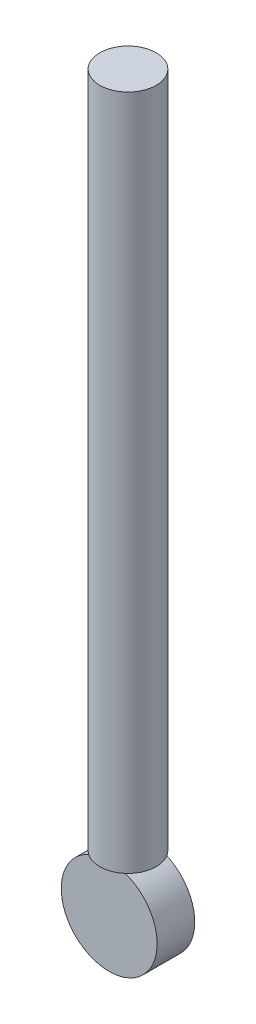
from build123d import *

# Parameters (mm, degrees)
SKETCH1_R           = 9.525
BOSS_EXTRUDE1_DEPTH = 228.6
SKETCH3_R           = 16.198016886
BOSS_EXTRUDE2_DEPTH = 6.35


with BuildPart() as part:
    # Sketch1 → Boss-Extrude1 (new body)
    with BuildSketch(Plane(origin=(0, 0, 0), x_dir=(1, 0, 0), z_dir=(0, 1, 0))):
        Circle(SKETCH1_R)
    extrude(amount=BOSS_EXTRUDE1_DEPTH)

    # Sketch3 → Boss-Extrude2 (add, symmetric)
    with BuildSketch(Plane.XY):
        with Locations((0, -16.03996745)):
            Circle(SKETCH3_R)
    extrude(amount=BOSS_EXTRUDE2_DEPTH, both=True)


solid = part.part
